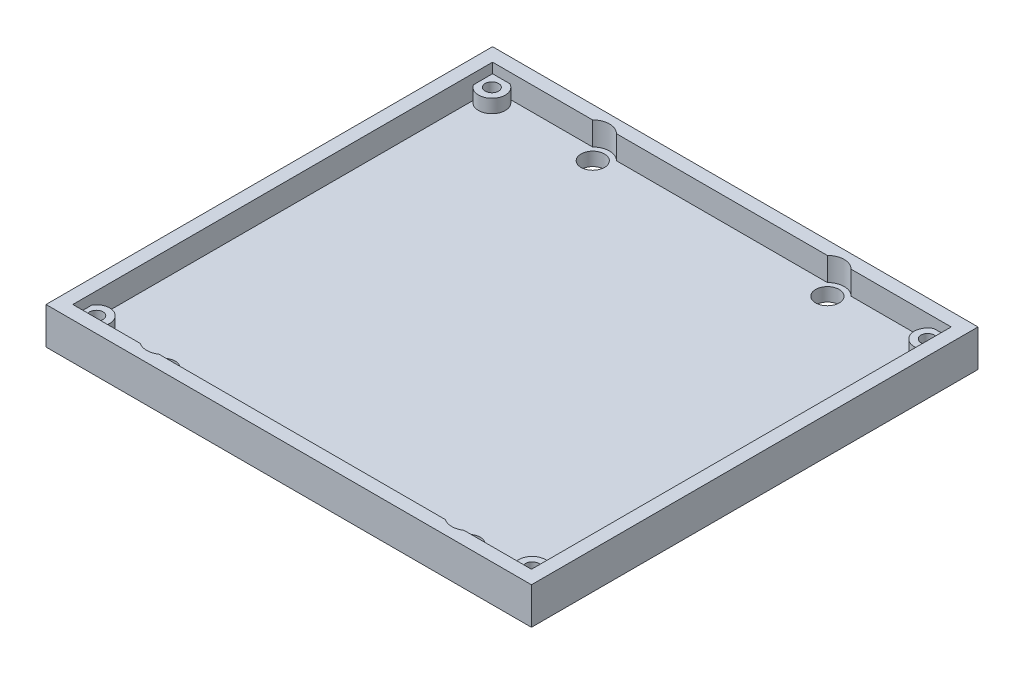
from build123d import *

# Parameters (mm, degrees)
SKETCH1_W           = 72.4
SKETCH1_H           = 66.6
SKETCH1_R           = 1.75
BOSS_EXTRUDE1_DEPTH = 2
SKETCH2_W           = 72.4
SKETCH2_H           = 66.6
SKETCH2_R           = 1
BOSS_EXTRUDE2_DEPTH = 2
SKETCH3_W           = 72.4
SKETCH3_H           = 66.6
BOSS_EXTRUDE3_DEPTH = 1.5


with BuildPart() as part:
    # Sketch1 → Boss-Extrude1 (new body)
    with BuildSketch(Plane(origin=(0, 0, 0), x_dir=(1, 0, 0), z_dir=(0, 1, 0))):
        with Locations((36.2, 33.3)):
            Rectangle(SKETCH1_W, SKETCH1_H)
        with Locations((18.7, 62.843663413)):
            Circle(SKETCH1_R, mode=Mode.SUBTRACT)
        with Locations((13.45, 4.077708133)):
            Circle(SKETCH1_R, mode=Mode.SUBTRACT)
        with Locations((58.95, 4.077708133)):
            Circle(SKETCH1_R, mode=Mode.SUBTRACT)
        with Locations((53.7, 62.843663413)):
            Circle(SKETCH1_R, mode=Mode.SUBTRACT)
    extrude(amount=BOSS_EXTRUDE1_DEPTH)

    # Sketch2 → Boss-Extrude2 (add)
    with BuildSketch(Plane(origin=(0, 2, 0), x_dir=(1, 0, 0), z_dir=(0, 1, 0))):
        with Locations((36.2, 33.3)):
            Rectangle(SKETCH2_W, SKETCH2_H)
        with Locations((3.7, 3.8)):
            Circle(SKETCH2_R, mode=Mode.SUBTRACT)
        with Locations((68.7, 3.8)):
            Circle(SKETCH2_R, mode=Mode.SUBTRACT)
        with Locations((3.7, 62.8)):
            Circle(SKETCH2_R, mode=Mode.SUBTRACT)
        with BuildLine():
            Line((12.059629936, 2), (4.571779789, 2))
            ThreePointArc((4.571779789, 2), (5.185663494, 5.138956303), (2, 4.853565375))
            Line((2, 4.853565375), (2, 61.746434625))
            ThreePointArc((2, 61.746434625), (5.185663494, 61.461043697), (4.571779789, 64.6))
            Line((4.571779789, 64.6), (16.920876117, 64.6))
            ThreePointArc((16.920876117, 64.6), (18.7, 65.343663413), (20.479123883, 64.6))
            Line((20.479123883, 64.6), (51.920876117, 64.6))
            ThreePointArc((51.920876117, 64.6), (53.7, 65.343663413), (55.479123883, 64.6))
            Line((55.479123883, 64.6), (67.828220211, 64.6))
            ThreePointArc((67.828220211, 64.6), (67.214336506, 61.461043697), (70.4, 61.746434625))
            Line((70.4, 61.746434625), (70.4, 4.853565375))
            ThreePointArc((70.4, 4.853565375), (67.214336506, 5.138956303), (67.828220211, 2))
            Line((67.828220211, 2), (60.340370064, 2))
            ThreePointArc((60.340370064, 2), (58.95, 1.577708133), (57.559629936, 2))
            Line((57.559629936, 2), (14.840370064, 2))
            ThreePointArc((14.840370064, 2), (13.45, 1.577708133), (12.059629936, 2))
        make_face(mode=Mode.SUBTRACT)
        with Locations((68.7, 62.8)):
            Circle(SKETCH2_R, mode=Mode.SUBTRACT)
    extrude(amount=BOSS_EXTRUDE2_DEPTH)

    # Sketch3 → Boss-Extrude3 (add)
    with BuildSketch(Plane(origin=(0, 4, 0), x_dir=(1, 0, 0), z_dir=(0, 1, 0))):
        with Locations((36.2, 33.3)):
            Rectangle(SKETCH3_W, SKETCH3_H)
        with BuildLine():
            Line((12.059629936, 2), (2, 2))
            Line((2, 2), (2, 64.6))
            Line((2, 64.6), (16.920876117, 64.6))
            ThreePointArc((16.920876117, 64.6), (18.7, 65.343663413), (20.479123883, 64.6))
            Line((20.479123883, 64.6), (51.920876117, 64.6))
            ThreePointArc((51.920876117, 64.6), (53.7, 65.343663413), (55.479123883, 64.6))
            Line((55.479123883, 64.6), (70.4, 64.6))
            Line((70.4, 64.6), (70.4, 2))
            Line((70.4, 2), (60.340370064, 2))
            ThreePointArc((60.340370064, 2), (58.95, 1.577708133), (57.559629936, 2))
            Line((57.559629936, 2), (14.840370064, 2))
            ThreePointArc((14.840370064, 2), (13.45, 1.577708133), (12.059629936, 2))
        make_face(mode=Mode.SUBTRACT)
    extrude(amount=BOSS_EXTRUDE3_DEPTH)


solid = part.part
